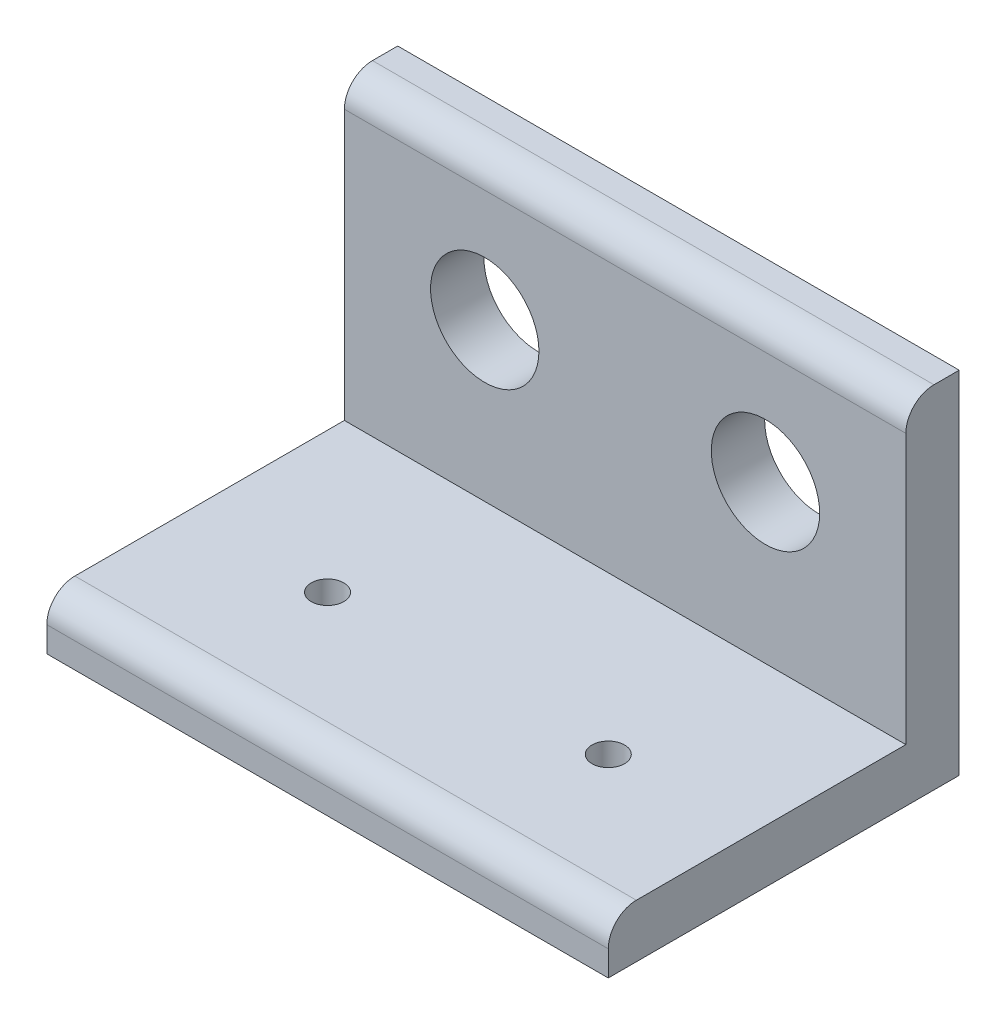
from build123d import *

# Parameters (mm, degrees)
BOSS_EXTRUDE1_DEPTH = 50.8
SKETCH3_R           = 4.9022
CUT_EXTRUDE1_DEPTH  = 50.8
SKETCH4_R           = 1.4732
CUT_EXTRUDE2_DEPTH  = 50.8
FILLET1_R           = 2.54


with BuildPart() as part:
    # Sketch2 → Boss-Extrude1 (new body)
    with BuildSketch(Plane(origin=(0, 0, 0), x_dir=(0, 0, -1), z_dir=(1, 0, 0))):
        Polygon((0, 0), (31.75, 0), (31.75, 31.75), (26.924, 31.75), (26.924, 4.826), (0, 4.826), align=None)
    extrude(amount=-BOSS_EXTRUDE1_DEPTH)

    # Sketch3 → Cut-Extrude1 (cut)
    with BuildSketch(Plane.XY.offset(-26.924)):
        with Locations((-38.1, 19.05)):
            Circle(SKETCH3_R)
        with Locations((-12.7, 19.05)):
            Circle(SKETCH3_R)
    extrude(amount=-CUT_EXTRUDE1_DEPTH, mode=Mode.SUBTRACT)

    # Sketch4 → Cut-Extrude2 (cut)
    with BuildSketch(Plane(origin=(0, 4.826, 0), x_dir=(1, 0, 0), z_dir=(0, 1, 0))):
        with Locations((-38.1, 12.7)):
            Circle(SKETCH4_R)
        with Locations((-12.7, 12.7)):
            Circle(SKETCH4_R)
    extrude(amount=-CUT_EXTRUDE2_DEPTH, mode=Mode.SUBTRACT)

    # Fillet1
    fillet1_edges = [part.edges().sort_by_distance(p)[0] for p in [
        (-25.4, 4.826, 0),
        (-25.4, 31.75, -26.924),
    ]]
    fillet(fillet1_edges, radius=FILLET1_R)


solid = part.part
